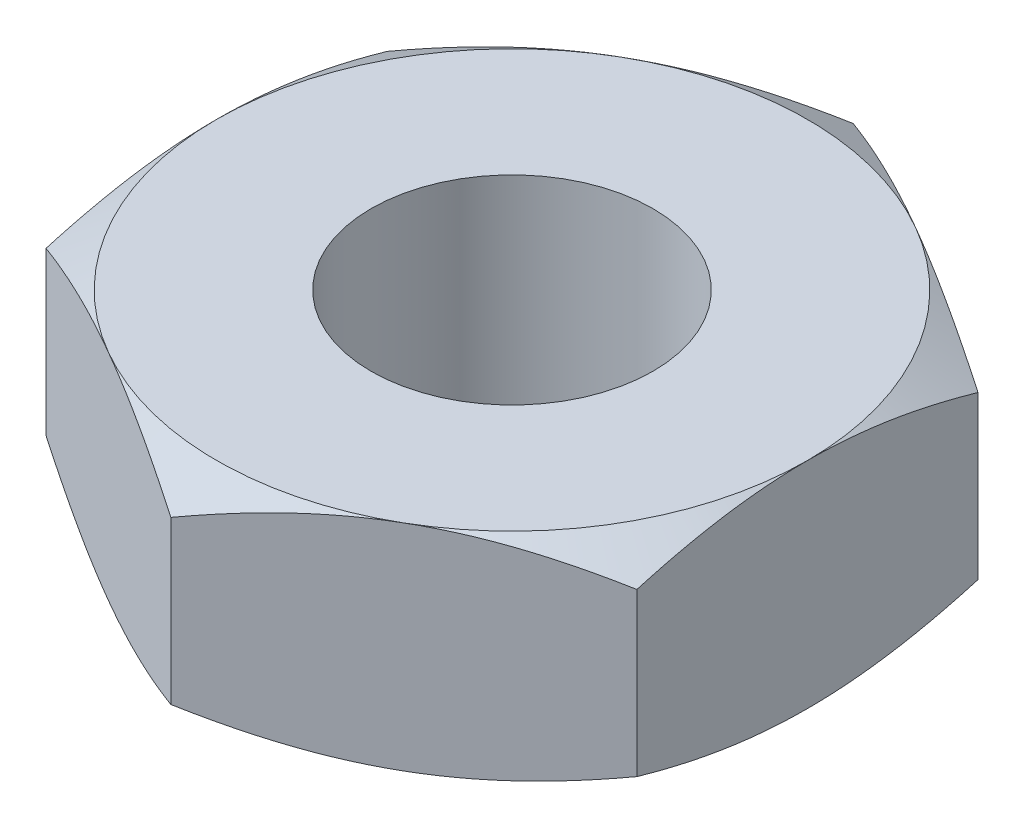
from build123d import *

# Parameters (mm, degrees)
SKETCH1_R               = 2.0828
BOSS_EXTRUDE1_DEPTH     = 1.5875
SKETCH5_OUTSIDE_W       = 42.524
SKETCH5_OUTSIDE_H       = 43.874
SKETCH5_OUTSIDE_R       = 4.365625
CUT_EXTRUDE2_DEPTH      = 8.385856901
CUT_EXTRUDE2_DRAFT      = -60
MIRROR1_COPY_1_SKETCH_W = 42.524
MIRROR1_COPY_1_SKETCH_H = 43.874
MIRROR1_COPY_1_SKETCH_R = 4.365625
MIRROR1_COPY_1_DEPTH    = 8.385856901
MIRROR1_COPY_1_DRAFT    = -60


with BuildPart() as part:
    # Sketch1 → Boss-Extrude1 (new, symmetric)
    with BuildSketch(Plane(origin=(0, 0, 0), x_dir=(1, 0, 0), z_dir=(0, 1, 0))):
        Polygon((-4.365625, 2.520494769), (-4.365625, -2.520494769), (0, -5.040989538), (4.365625, -2.520494769), (4.365625, 2.520494769), (0, 5.040989538), align=None)
        Circle(SKETCH1_R, mode=Mode.SUBTRACT)
    extrude(amount=BOSS_EXTRUDE1_DEPTH, both=True)


with BuildPart() as cut_extrude2_tool:
    # Sketch5 outside → Cut-Extrude2 (with draft: the straight prism first)
    with BuildSketch(Plane(origin=(0, 1.5875, 0), x_dir=(1, 0, 0), z_dir=(0, 1, 0))):
        Rectangle(SKETCH5_OUTSIDE_W, SKETCH5_OUTSIDE_H)
        Circle(SKETCH5_OUTSIDE_R, mode=Mode.SUBTRACT)
    extrude(amount=-CUT_EXTRUDE2_DEPTH)
    # Cut-Extrude2: the draft: its side faces are tilted about the plane it starts from
    cut_extrude2_sides = [cut_extrude2_tool.faces().sort_by_distance(p)[0] for p in [
        (0, -2.60542845, 21.937),
        (21.262, -2.60542845, 0),
        (0, -2.60542845, -21.937),
        (-21.262, -2.60542845, 0),
        (-4.365625, -2.60542845, 0),
    ]]
    draft(cut_extrude2_sides, Plane(origin=(0, 1.5875, 0), x_dir=(1, 0, 0), z_dir=(0, 1, 0)), CUT_EXTRUDE2_DRAFT)


with BuildPart() as part_1:
    add(part.part)

    # Cut-Extrude2: cut by cut_extrude2_tool
    add(cut_extrude2_tool.part, mode=Mode.SUBTRACT)


with BuildPart() as mirror1_copy_1_tool:
    # Mirror1 copy 1 sketch → Mirror1 copy 1 (with draft: the straight prism first)
    with BuildSketch(Plane.XZ.offset(1.5875)):
        Rectangle(MIRROR1_COPY_1_SKETCH_W, MIRROR1_COPY_1_SKETCH_H)
        Circle(MIRROR1_COPY_1_SKETCH_R, mode=Mode.SUBTRACT)
    extrude(amount=-MIRROR1_COPY_1_DEPTH)
    # Mirror1 copy 1: the draft: its side faces are tilted about the plane it starts from
    mirror1_copy_1_sides = [mirror1_copy_1_tool.faces().sort_by_distance(p)[0] for p in [
        (0, 2.60542845, 21.937),
        (21.262, 2.60542845, 0),
        (0, 2.60542845, -21.937),
        (-21.262, 2.60542845, 0),
        (-4.365625, 2.60542845, 0),
    ]]
    draft(mirror1_copy_1_sides, Plane.XZ.offset(1.5875), MIRROR1_COPY_1_DRAFT)


with BuildPart() as part_2:
    add(part_1.part)

    # Mirror1 copy 1: cut by mirror1_copy_1_tool
    add(mirror1_copy_1_tool.part, mode=Mode.SUBTRACT)


solid = part_2.part
